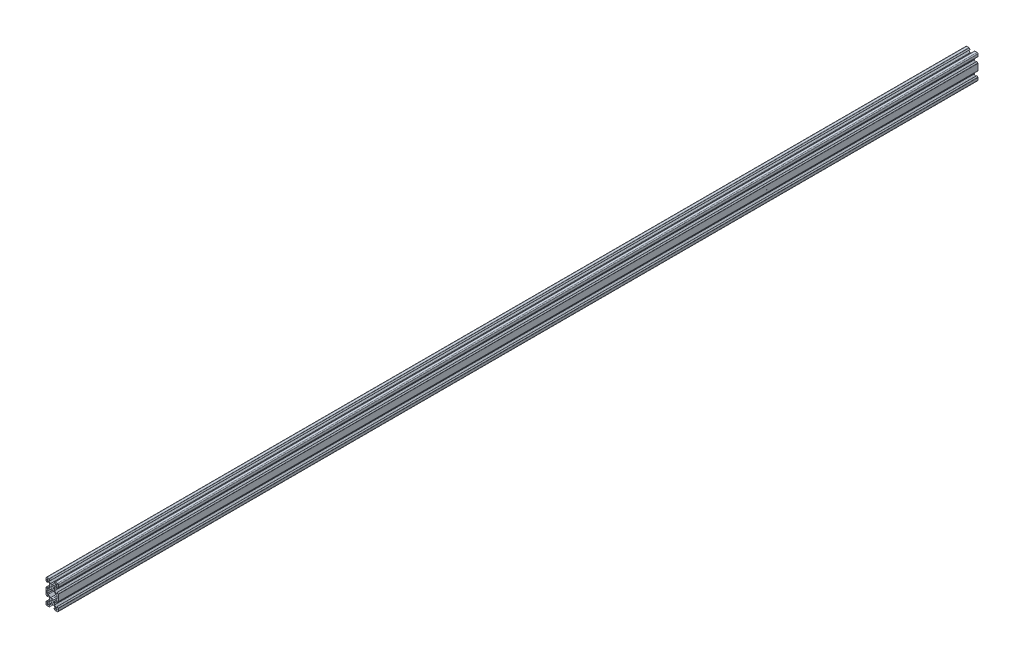
from build123d import *

# Parameters (mm, degrees)
SKETCH2_R           = 2.1
BOSS_EXTRUDE1_DEPTH = 1500


with BuildPart() as part:
    # Sketch2 → Boss-Extrude1 (new body)
    with BuildSketch(Plane.XY):
        with BuildLine():
            Line((-0.1, 3.9), (0, 3.8))
            Line((0, 3.8), (0.1, 3.9))
            Line((0.1, 3.9), (2.840365134, 3.9))
            Line((2.840365134, 3.9), (5.5, 6.558825842))
            Line((5.5, 6.558825842), (5.5, 8.197505675))
            Line((5.5, 8.197505675), (2.89, 8.197505675))
            Line((2.89, 8.197505675), (2.89, 8.307505675))
            Line((2.89, 8.307505675), (4.348614357, 9.766120032))
            ThreePointArc((4.348614357, 9.766120032), (4.604908803, 9.937370505), (4.907228714, 9.997505675))
            Line((4.907228714, 9.997505675), (8.5, 9.997505675))
            ThreePointArc((8.5, 9.997505675), (9.560660172, 9.558165846), (10, 8.497505675))
            Line((10, 8.497505675), (10, 4.904734389))
            ThreePointArc((10, 4.904734389), (9.939864831, 4.602414477), (9.768614357, 4.346120032))
            Line((9.768614357, 4.346120032), (8.31, 2.887505675))
            Line((8.31, 2.887505675), (8.2, 2.887505675))
            Line((8.2, 2.887505675), (8.2, 5.497505675))
            Line((8.2, 5.497505675), (6.56, 5.497505675))
            Line((6.56, 5.497505675), (3.9, 2.83831481))
            Line((3.9, 2.83831481), (3.9, 0.1))
            Line((3.9, 0.1), (3.8, 0))
            Line((3.8, 0), (3.9, -0.1))
            Line((3.9, -0.1), (3.9, -2.84))
            Line((3.9, -2.84), (6.56, -5.5))
            Line((6.56, -5.5), (8.2, -5.5))
            Line((8.2, -5.5), (8.2, -2.89))
            Line((8.2, -2.89), (8.31, -2.89))
            Line((8.31, -2.89), (9.765685425, -4.345685425))
            ThreePointArc((9.765685425, -4.345685425), (9.939103626, -4.605224104), (10, -4.91137085))
            Line((10, -4.91137085), (10, -15.08862915))
            ThreePointArc((10, -15.08862915), (9.939103626, -15.394775896), (9.765685425, -15.654314575))
            Line((9.765685425, -15.654314575), (8.31, -17.11))
            Line((8.31, -17.11), (8.2, -17.11))
            Line((8.2, -17.11), (8.2, -14.5))
            Line((8.2, -14.5), (6.56, -14.5))
            Line((6.56, -14.5), (3.9, -17.16))
            Line((3.9, -17.16), (3.9, -19.9))
            Line((3.9, -19.9), (3.8, -20))
            Line((3.8, -20), (3.9, -20.1))
            Line((3.9, -20.1), (3.9, -22.83831481))
            Line((3.9, -22.83831481), (6.56, -25.497505675))
            Line((6.56, -25.497505675), (8.2, -25.497505675))
            Line((8.2, -25.497505675), (8.2, -22.887505675))
            Line((8.2, -22.887505675), (8.31, -22.887505675))
            Line((8.31, -22.887505675), (9.768614357, -24.346120032))
            ThreePointArc((9.768614357, -24.346120032), (9.939864831, -24.602414477), (10, -24.904734389))
            Line((10, -24.904734389), (10, -28.497505675))
            ThreePointArc((10, -28.497505675), (9.560660172, -29.558165846), (8.5, -29.997505675))
            Line((8.5, -29.997505675), (4.907228714, -29.997505675))
            ThreePointArc((4.907228714, -29.997505675), (4.604908803, -29.937370505), (4.348614357, -29.766120032))
            Line((4.348614357, -29.766120032), (2.89, -28.307505675))
            Line((2.89, -28.307505675), (2.89, -28.197505675))
            Line((2.89, -28.197505675), (5.5, -28.197505675))
            Line((5.5, -28.197505675), (5.5, -26.558825842))
            Line((5.5, -26.558825842), (2.840365134, -23.9))
            Line((2.840365134, -23.9), (0.1, -23.9))
            Line((0.1, -23.9), (0, -23.8))
            Line((0, -23.8), (-0.1, -23.9))
            Line((-0.1, -23.9), (-2.840365134, -23.9))
            Line((-2.840365134, -23.9), (-5.5, -26.558825842))
            Line((-5.5, -26.558825842), (-5.5, -28.197505675))
            Line((-5.5, -28.197505675), (-2.89, -28.197505675))
            Line((-2.89, -28.197505675), (-2.89, -28.307505675))
            Line((-2.89, -28.307505675), (-4.348614357, -29.766120032))
            ThreePointArc((-4.348614357, -29.766120032), (-4.604908803, -29.937370505), (-4.907228714, -29.997505675))
            Line((-4.907228714, -29.997505675), (-8.5, -29.997505675))
            ThreePointArc((-8.5, -29.997505675), (-9.560660172, -29.558165846), (-10, -28.497505675))
            Line((-10, -28.497505675), (-10, -24.904734389))
            ThreePointArc((-10, -24.904734389), (-9.939864831, -24.602414477), (-9.768614357, -24.346120032))
            Line((-9.768614357, -24.346120032), (-8.31, -22.887505675))
            Line((-8.31, -22.887505675), (-8.2, -22.887505675))
            Line((-8.2, -22.887505675), (-8.2, -25.497505675))
            Line((-8.2, -25.497505675), (-6.56, -25.497505675))
            Line((-6.56, -25.497505675), (-3.9, -22.83831481))
            Line((-3.9, -22.83831481), (-3.9, -20.1))
            Line((-3.9, -20.1), (-3.8, -20))
            Line((-3.8, -20), (-3.9, -19.9))
            Line((-3.9, -19.9), (-3.9, -17.16))
            Line((-3.9, -17.16), (-6.56, -14.5))
            Line((-6.56, -14.5), (-8.2, -14.5))
            Line((-8.2, -14.5), (-8.2, -17.11))
            Line((-8.2, -17.11), (-8.31, -17.11))
            Line((-8.31, -17.11), (-9.765685425, -15.654314575))
            ThreePointArc((-9.765685425, -15.654314575), (-9.939103626, -15.394775896), (-10, -15.08862915))
            Line((-10, -15.08862915), (-10, -4.91137085))
            ThreePointArc((-10, -4.91137085), (-9.939103626, -4.605224104), (-9.765685425, -4.345685425))
            Line((-9.765685425, -4.345685425), (-8.31, -2.89))
            Line((-8.31, -2.89), (-8.2, -2.89))
            Line((-8.2, -2.89), (-8.2, -5.5))
            Line((-8.2, -5.5), (-6.56, -5.5))
            Line((-6.56, -5.5), (-3.9, -2.84))
            Line((-3.9, -2.84), (-3.9, -0.1))
            Line((-3.9, -0.1), (-3.8, 0))
            Line((-3.8, 0), (-3.9, 0.1))
            Line((-3.9, 0.1), (-3.9, 2.83831481))
            Line((-3.9, 2.83831481), (-6.56, 5.497505675))
            Line((-6.56, 5.497505675), (-8.2, 5.497505675))
            Line((-8.2, 5.497505675), (-8.2, 2.887505675))
            Line((-8.2, 2.887505675), (-8.31, 2.887505675))
            Line((-8.31, 2.887505675), (-9.768614357, 4.346120032))
            ThreePointArc((-9.768614357, 4.346120032), (-9.939864831, 4.602414477), (-10, 4.904734389))
            Line((-10, 4.904734389), (-10, 8.497505675))
            ThreePointArc((-10, 8.497505675), (-9.560660172, 9.558165846), (-8.5, 9.997505675))
            Line((-8.5, 9.997505675), (-4.907228714, 9.997505675))
            ThreePointArc((-4.907228714, 9.997505675), (-4.604908803, 9.937370505), (-4.348614357, 9.766120032))
            Line((-4.348614357, 9.766120032), (-2.89, 8.307505675))
            Line((-2.89, 8.307505675), (-2.89, 8.197505675))
            Line((-2.89, 8.197505675), (-5.5, 8.197505675))
            Line((-5.5, 8.197505675), (-5.5, 6.558825842))
            Line((-5.5, 6.558825842), (-2.840365134, 3.9))
            Line((-2.840365134, 3.9), (-0.1, 3.9))
        make_face()
        Circle(SKETCH2_R, mode=Mode.SUBTRACT)
        with Locations((0, -20)):
            Circle(SKETCH2_R, mode=Mode.SUBTRACT)
        Polygon((-7.66, 6.567505675), (-6.57, 7.657505675), (-6.57, 8.197505675), (-8.2, 8.197505675), (-8.2, 6.567505675), align=None, mode=Mode.SUBTRACT)
        Polygon((-0.1, -3.9), (0, -3.8), (0.1, -3.9), (2.840365134, -3.9), (6.24, -7.299634866), (8.2, -7.299634866), (8.2, -12.700365134), (6.24, -12.700365134), (2.840365134, -16.1), (0.1, -16.1), (0, -16.2), (-0.1, -16.1), (-2.840365134, -16.1), (-6.24, -12.700365134), (-8.2, -12.700365134), (-8.2, -7.299634866), (-6.24, -7.299634866), (-2.840365134, -3.9), align=None, mode=Mode.SUBTRACT)
        Polygon((8.2, 6.567505675), (7.66, 6.567505675), (6.57, 7.657505675), (6.57, 8.197505675), (8.2, 8.197505675), align=None, mode=Mode.SUBTRACT)
        Polygon((7.66, -26.567505675), (6.57, -27.657505675), (6.57, -28.197505675), (8.2, -28.197505675), (8.2, -26.567505675), align=None, mode=Mode.SUBTRACT)
        Polygon((-8.2, -26.567505675), (-7.66, -26.567505675), (-6.57, -27.657505675), (-6.57, -28.197505675), (-8.2, -28.197505675), align=None, mode=Mode.SUBTRACT)
    extrude(amount=-BOSS_EXTRUDE1_DEPTH)


solid = part.part
